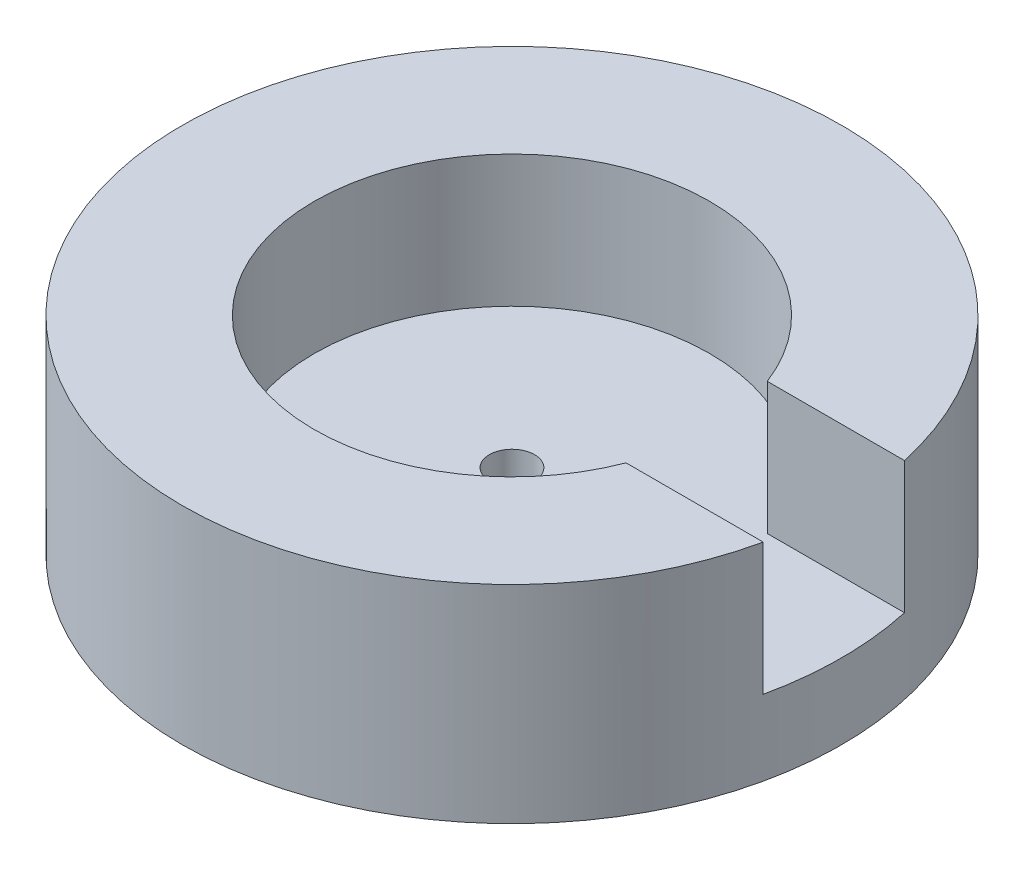
from build123d import *

# Parameters (mm, degrees)
SKETCH2_R           = 17.5
BOSS_EXTRUDE1_DEPTH = 4
BOSS_EXTRUDE2_START = 7
BOSS_EXTRUDE2_DEPTH = 7
SKETCH2_4_R         = 1.2
CUT_EXTRUDE1_DEPTH  = 1.5


with BuildPart() as part:
    # Sketch2 → Boss-Extrude1 (new body)
    with BuildSketch(Plane(origin=(0, 0, 0), x_dir=(1, 0, 0), z_dir=(0, 1, 0))):
        Circle(SKETCH2_R)
    extrude(amount=-BOSS_EXTRUDE1_DEPTH)

    # Sketch2_3 → Boss-Extrude2 (add)
    with BuildSketch(Plane(origin=(0, 0, 0), x_dir=(1, 0, 0), z_dir=(0, 1, 0)).offset(BOSS_EXTRUDE2_START)):
        with BuildLine():
            Line((17.093492914, -3.75), (9.807522623, -3.75))
            ThreePointArc((9.807522623, -3.75), (-10.5, 0), (9.807522623, 3.75))
            Line((9.807522623, 3.75), (17.093492914, 3.75))
            ThreePointArc((17.093492914, 3.75), (-17.5, 0), (17.093492914, -3.75))
        make_face()
    extrude(amount=-BOSS_EXTRUDE2_DEPTH)

    # Sketch2_4 → Cut-Extrude1 (cut)
    with BuildSketch(Plane(origin=(0, 0, 0), x_dir=(1, 0, 0), z_dir=(0, 1, 0))):
        Circle(SKETCH2_4_R)
    extrude(amount=-CUT_EXTRUDE1_DEPTH, mode=Mode.SUBTRACT)


solid = part.part
